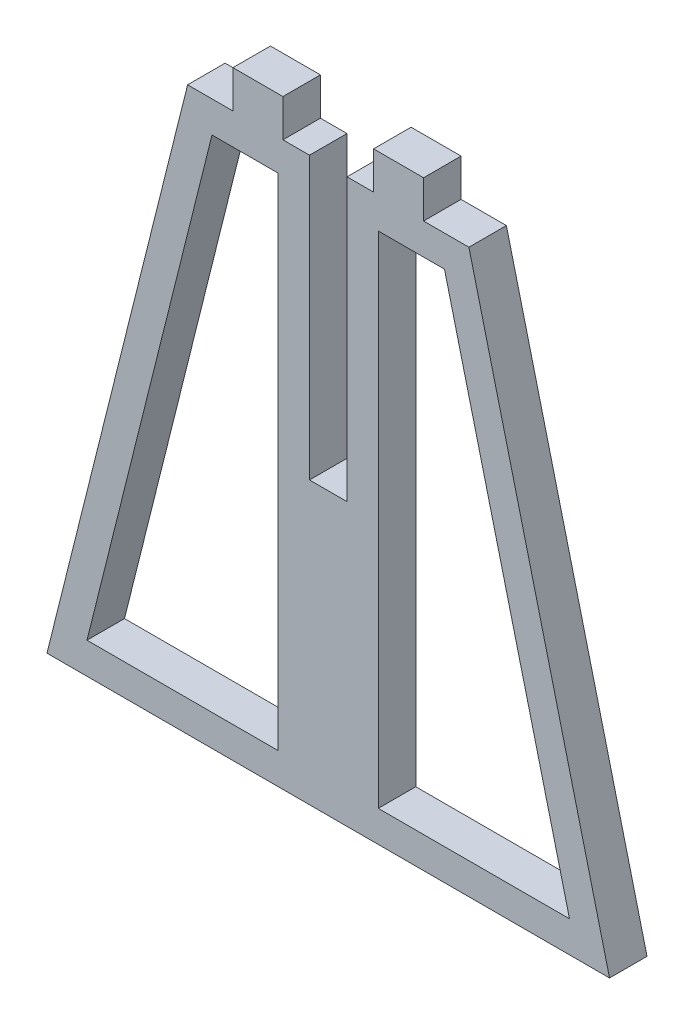
from build123d import *

# Parameters (mm, degrees)
BOSS_EXTRUDE1_DEPTH = 6


with BuildPart() as part:
    # Sketch1 → Boss-Extrude1 (new body)
    with BuildSketch(Plane.XY):
        Polygon((45, 15.633986602), (-45, 15.633986602), (-22.5, 105.633986602), (-15.25, 105.633986602), (-15.25, 111.633986602), (-7.25, 111.633986602), (-7.25, 105.633986602), (-3, 105.633986602), (-3, 60.633986602), (3, 60.633986602), (3, 105.633986602), (7.25, 105.633986602), (7.25, 111.633986602), (15.25, 111.633986602), (15.25, 105.633986602), (22.5, 105.633986602), align=None)
        Polygon((-8, 100.633986602), (-18.596117968, 100.633986602), (-38.596117968, 20.633986602), (-8, 20.633986602), align=None, mode=Mode.SUBTRACT)
        Polygon((38.596117968, 20.633986602), (8, 20.633986602), (8, 100.633986602), (18.596117968, 100.633986602), align=None, mode=Mode.SUBTRACT)
    extrude(amount=BOSS_EXTRUDE1_DEPTH)


solid = part.part
